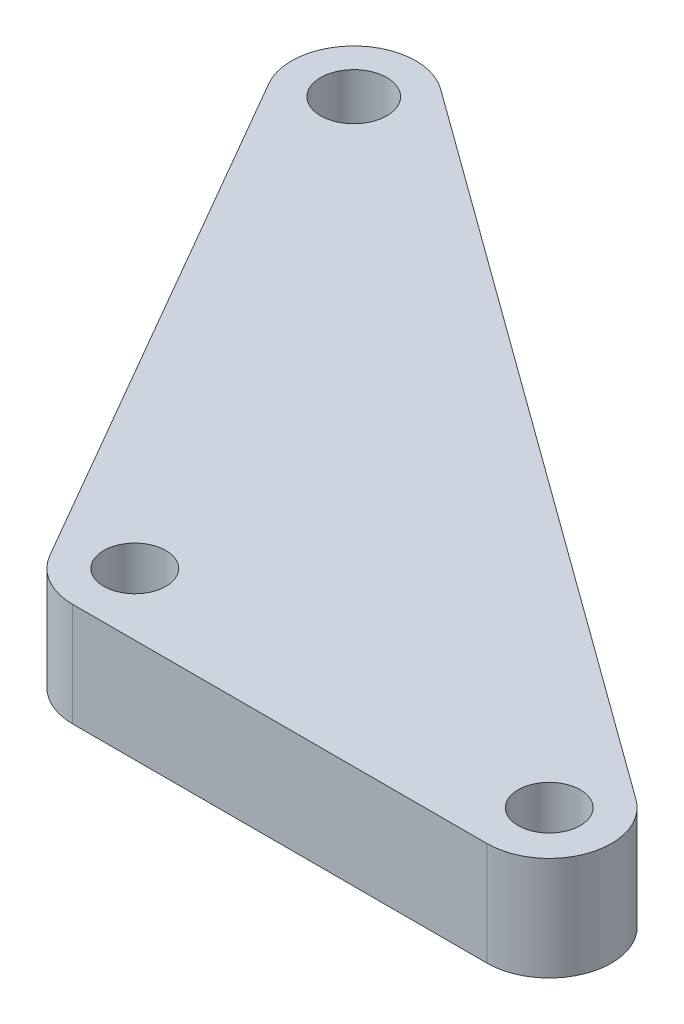
from build123d import *

# Parameters (mm, degrees)
SKETCH2_R           = 1.6
SKETCH2_R_2         = 1.5
BOSS_EXTRUDE2_DEPTH = 5
FILLET1_R           = 3


with BuildPart() as part:
    # Sketch2 → Boss-Extrude2 (new body)
    with BuildSketch(Plane(origin=(0, 0, 0), x_dir=(1, 0, 0), z_dir=(0, 1, 0))):
        Polygon((12.701705922, -28), (43.672062905, -28), (-9.649224004, 10.712946228), align=None)
        Circle(SKETCH2_R, mode=Mode.SUBTRACT)
        with Locations((14.43375673, -25)):
            Circle(SKETCH2_R_2, mode=Mode.SUBTRACT)
        with Locations((34.43375673, -25)):
            Circle(SKETCH2_R_2, mode=Mode.SUBTRACT)
    extrude(amount=BOSS_EXTRUDE2_DEPTH)

    # Fillet1
    fillet1_edges = [part.edges().sort_by_distance(p)[0] for p in [
        (43.672062905, 2.5, 28),
        (12.701705922, 2.5, 28),
        (-9.649224004, 2.5, -10.712946228),
    ]]
    fillet(fillet1_edges, radius=FILLET1_R)


solid = part.part
